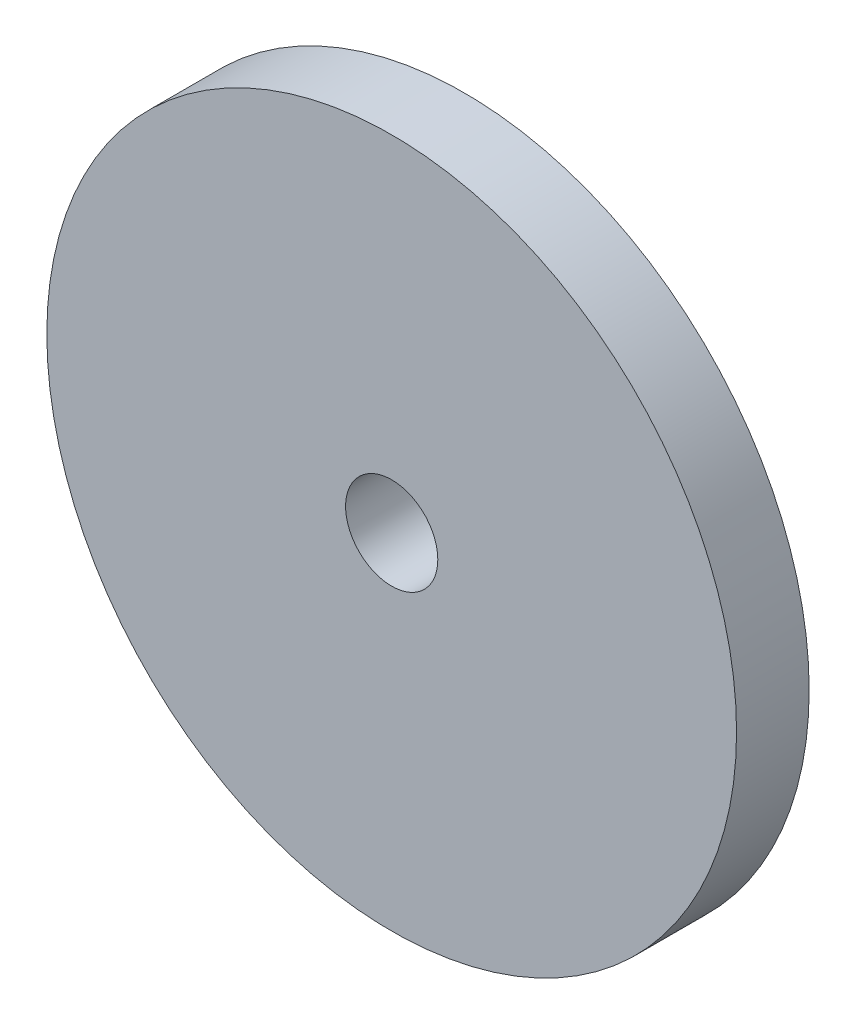
from build123d import *

# Parameters (mm, degrees)
SKETCH2_R           = 47.5
SKETCH2_R_2         = 6.35
BOSS_EXTRUDE1_DEPTH = 10


with BuildPart() as part:
    # Sketch2 → Boss-Extrude1 (new body)
    with BuildSketch(Plane.XY):
        Circle(SKETCH2_R)
        Circle(SKETCH2_R_2, mode=Mode.SUBTRACT)
    extrude(amount=BOSS_EXTRUDE1_DEPTH)


solid = part.part
